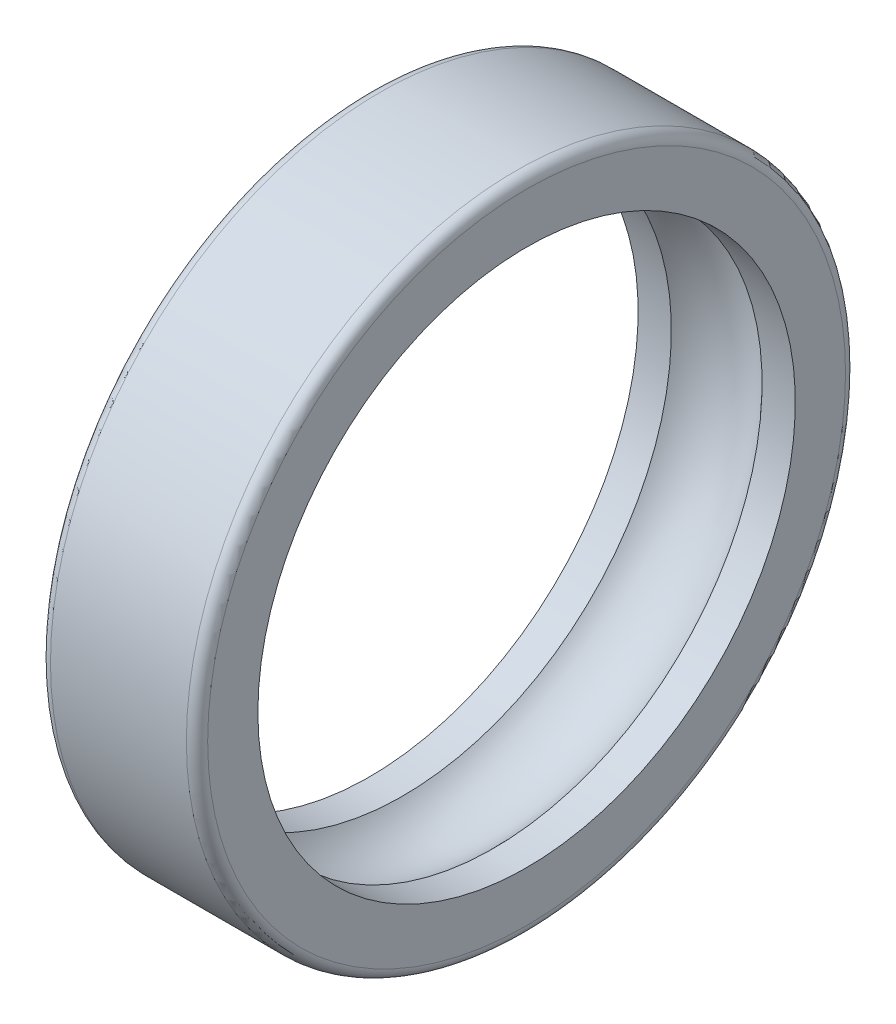
from build123d import *

# Parameters (mm, degrees)
FILLET1_R = 2.1


with BuildPart() as part:
    # Sketch1 → Revolve1 (revolve)
    with BuildSketch(Plane.XY):
        with BuildLine():
            Line((15.5, 65), (-15.5, 65))
            Line((-15.5, 65), (-15.5, 53))
            Line((-15.5, 53), (-8.94427191, 53))
            ThreePointArc((-8.94427191, 53), (0, 57), (8.94427191, 53))
            Line((8.94427191, 53), (15.5, 53))
            Line((15.5, 53), (15.5, 65))
        make_face()
    revolve(axis=Axis((-14.017800128, 0, 0), (1, 0, 0)))

    # Fillet1
    fillet1_edges = [part.edges().sort_by_distance(p)[0] for p in [
        (-15.5, -65, 0),
        (15.5, -65, 0),
    ]]
    fillet(fillet1_edges, radius=FILLET1_R)


solid = part.part
